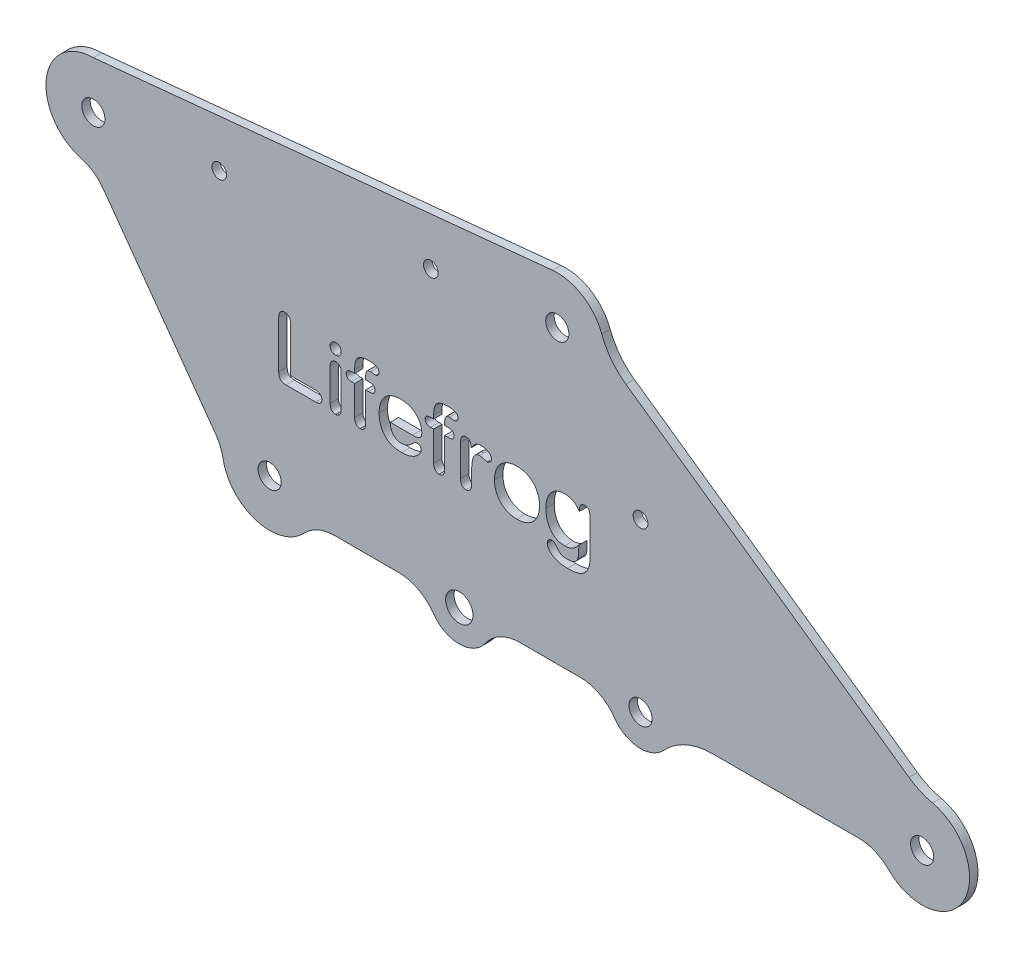
from build123d import *

# Parameters (mm, degrees)
SKETCH2_R           = 2.75
SKETCH2_R_2         = 3.25
BOSS_EXTRUDE1_DEPTH = 2
SKETCH7_R           = 1.75
CUT_EXTRUDE4_DEPTH  = 3
CUT_EXTRUDE5_DEPTH  = 10
SKETCH8_R           = 4.443707928
SKETCH8_R_2         = 3.98713944
CUT_EXTRUDE6_DEPTH  = 10


with BuildPart() as part:
    # Sketch2 → Boss-Extrude1 (new body)
    with BuildSketch(Plane.XY):
        with BuildLine():
            Line((-146.482261324, -3.415116213), (-119.900209046, -40.345357838))
            ThreePointArc((-119.900209046, -40.345357838), (-118.800607084, -42.305283789), (-118.166440512, -44.46126778))
            ThreePointArc((-118.166440512, -44.46126778), (-110.313224995, -53.296457195), (-98.896144571, -50.233151699))
            ThreePointArc((-98.896144571, -50.233151699), (-95.581387, -47.909162096), (-91.616909182, -47.089734824))
            Line((-91.616909182, -47.089734824), (-76.446691, -47.089734824))
            ThreePointArc((-76.446691, -47.089734824), (-71.817590501, -48.22568222), (-68.240172934, -51.37544911))
            ThreePointArc((-68.240172934, -51.37544911), (-62.085284384, -54.589734824), (-55.930395834, -51.37544911))
            ThreePointArc((-55.930395834, -51.37544911), (-52.352978266, -48.22568222), (-47.723877768, -47.089734824))
            Line((-47.723877768, -47.089734824), (-33.446691, -47.089734824))
            ThreePointArc((-33.446691, -47.089734824), (-28.817590501, -48.22568222), (-25.240172934, -51.37544911))
            ThreePointArc((-25.240172934, -51.37544911), (-19.593639667, -54.572486651), (-13.566591065, -52.168516573))
            ThreePointArc((-13.566591065, -52.168516573), (-8.311100334, -48.415273127), (-1.990501675, -47.089734824))
            Line((-1.990501675, -47.089734824), (32.686636747, -47.089734824))
            ThreePointArc((32.686636747, -47.089734824), (36.521461692, -47.854253372), (39.769927676, -50.030911295))
            ThreePointArc((39.769927676, -50.030911295), (57.590414229, -47.521571248), (50.200722675, -31.112458317))
            ThreePointArc((50.200722675, -31.112458317), (47.278407153, -30.14859154), (44.599620096, -28.63430389))
            Line((44.599620096, -28.63430389), (-22.564700668, 18.554547573))
            ThreePointArc((-22.564700668, 18.554547573), (-25.986792869, 21.830620173), (-28.278442139, 25.976908916))
            ThreePointArc((-28.278442139, 25.976908916), (-32.864492812, 31.616465892), (-39.941717654, 33.27458296))
            Line((-39.941717654, 33.27458296), (-148.918739614, 22.469864413))
            ThreePointArc((-148.918739614, 22.469864413), (-160.065949313, 12.737169894), (-151.925623591, 0.379147243))
            ThreePointArc((-151.925623591, 0.379147243), (-148.880072017, -1.053350399), (-146.482261324, -3.415116213))
        make_face()
        with Locations((47.738629971, -42.089734824)):
            Circle(SKETCH2_R, mode=Mode.SUBTRACT)
        with Locations((-19.085284384, -47.089734824)):
            Circle(SKETCH2_R, mode=Mode.SUBTRACT)
        with Locations((-62.085284384, -47.089734824)):
            Circle(SKETCH2_R_2, mode=Mode.SUBTRACT)
        with Locations((-107.085284384, -42.519495684)):
            Circle(SKETCH2_R, mode=Mode.SUBTRACT)
        with Locations((-148.918739614, 11.219864413)):
            Circle(SKETCH2_R, mode=Mode.SUBTRACT)
        with Locations((-38.831758764, 22.07947281)):
            Circle(SKETCH2_R, mode=Mode.SUBTRACT)
    extrude(amount=BOSS_EXTRUDE1_DEPTH)

    # Sketch7 → Cut-Extrude4 (cut, through all)
    with BuildSketch(Plane.XY.offset(2)):
        with Locations((-119.063647537, 14.164941171)):
            Circle(SKETCH7_R)
        with Locations((-68.831758764, 19.120101507)):
            Circle(SKETCH7_R)
        with Locations((-19.085284384, -7.519495684)):
            Circle(SKETCH7_R)
    extrude(amount=-CUT_EXTRUDE4_DEPTH, mode=Mode.SUBTRACT)

    # Sketch5 → Cut-Extrude5 (cut)
    with BuildSketch(Plane.XY.offset(2)):
        with BuildLine():
            Line((-102.115894244, -8.88917677), (-102.115894244, -19.477067395))
            Line((-102.115894244, -19.477067395), (-96.162769244, -19.477067395))
            add(Edge.make_bspline(
                [(-96.162769244, -19.477067395), (-96.051007313, -19.479993195), (-95.837884188, -19.485572515), (-95.539916783, -19.554542719), (-95.278875028, -19.661257744), (-95.067813968, -19.819951832), (-94.897692681, -20.005566477), (-94.774137444, -20.217869304), (-94.701867925, -20.454899643), (-94.69344353, -20.620129964), (-94.689136431, -20.704606457)],
                knots=[0, 0, 0, 0, 0.000334613, 0.000638087, 0.000912369, 0.001174294, 0.001423196, 0.001663395, 0.001905285, 0.002158326, 0.002158326, 0.002158326, 0.002158326], degree=3))
            add(Edge.make_bspline(
                [(-94.689136431, -20.704606457), (-94.693268201, -20.791061883), (-94.701260642, -20.958300126), (-94.774223839, -21.197153566), (-94.896313466, -21.407864411), (-95.064278317, -21.589554136), (-95.275076024, -21.739731647), (-95.534926018, -21.839448431), (-95.834238111, -21.905877279), (-96.049070498, -21.911559901), (-96.162769244, -21.914567395)],
                knots=[0, 0, 0, 0, 0.000258876, 0.000500766, 0.000740964, 0.000983563, 0.001237974, 0.001509993, 0.00181283, 0.002153292, 0.002153292, 0.002153292, 0.002153292], degree=3))
            Line((-96.162769244, -21.914567395), (-103.205737994, -21.914567395))
            add(Edge.make_bspline(
                [(-103.205737994, -21.914567395), (-103.348861132, -21.910822677), (-103.615411062, -21.903848583), (-103.983050705, -21.820051925), (-104.292130258, -21.691568649), (-104.538399287, -21.496286799), (-104.719909675, -21.2361672), (-104.844114456, -20.915092293), (-104.914328704, -20.530846545), (-104.923491067, -20.25471837), (-104.928394244, -20.106950207)],
                knots=[0, 0, 0, 0, 0.000428546, 0.000798117, 0.001124734, 0.001424881, 0.001727306, 0.002065149, 0.00245011, 0.002893278, 0.002893278, 0.002893278, 0.002893278], degree=3))
            Line((-104.928394244, -20.106950207), (-104.928394244, -8.88917677))
            add(Edge.make_bspline(
                [(-104.928394244, -8.88917677), (-104.924770448, -8.749162056), (-104.917946116, -8.485486372), (-104.845257533, -8.118037422), (-104.725580552, -7.804802622), (-104.557073154, -7.546892469), (-104.345359797, -7.348035389), (-104.103133358, -7.202614303), (-103.828238086, -7.118889739), (-103.635988236, -7.107793002), (-103.536792681, -7.102067395)],
                knots=[0, 0, 0, 0, 0.0004196, 0.000790191, 0.001117701, 0.00141997, 0.001705972, 0.001981814, 0.00226075, 0.002558095, 0.002558095, 0.002558095, 0.002558095], degree=3))
            add(Edge.make_bspline(
                [(-103.536792681, -7.102067395), (-103.435486672, -7.106162598), (-103.238729888, -7.114116312), (-102.960533725, -7.204196573), (-102.711018875, -7.34317393), (-102.496727467, -7.541754535), (-102.319699564, -7.795771782), (-102.199312355, -8.111096688), (-102.125957592, -8.481501141), (-102.119399349, -8.747181708), (-102.115894244, -8.88917677)],
                knots=[0, 0, 0, 0, 0.000302908, 0.000588308, 0.000867752, 0.001153903, 0.001457037, 0.001788351, 0.002158942, 0.002584392, 0.002584392, 0.002584392, 0.002584392], degree=3))
        make_face()
        with BuildLine():
            Line((-90.115894244, -12.74464552), (-90.115894244, -20.476090832))
            add(Edge.make_bspline(
                [(-90.115894244, -20.476090832), (-90.119794378, -20.602435528), (-90.127150905, -20.84074997), (-90.197032734, -21.174236118), (-90.314116621, -21.460321774), (-90.479508659, -21.694972614), (-90.682688675, -21.876468441), (-90.91257444, -22.009165841), (-91.170561441, -22.087195916), (-91.35072121, -22.097028675), (-91.443042681, -22.102067395)],
                knots=[0, 0, 0, 0, 0.000378656, 0.00071423, 0.001016215, 0.001299911, 0.001567541, 0.00182736, 0.002090575, 0.002367225, 0.002367225, 0.002367225, 0.002367225], degree=3))
            add(Edge.make_bspline(
                [(-91.443042681, -22.102067395), (-91.535510198, -22.097531408), (-91.714376796, -22.08875712), (-91.96856286, -22.004912745), (-92.195763486, -21.871389965), (-92.391201556, -21.682373157), (-92.551255931, -21.445866625), (-92.661127298, -21.160395096), (-92.729043835, -20.832780478), (-92.736793903, -20.599508451), (-92.740894244, -20.476090832)],
                knots=[0, 0, 0, 0, 0.00027665, 0.000535144, 0.000793904, 0.001061213, 0.001343984, 0.001643744, 0.001972979, 0.002342863, 0.002342863, 0.002342863, 0.002342863], degree=3))
            Line((-92.740894244, -20.476090832), (-92.740894244, -12.823747082))
            add(Edge.make_bspline(
                [(-92.740894244, -12.823747082), (-92.736699871, -12.699382119), (-92.728769083, -12.464230884), (-92.662517274, -12.136087305), (-92.551799881, -11.854229206), (-92.391012747, -11.625466775), (-92.194397213, -11.44586487), (-91.968144037, -11.317596829), (-91.713355602, -11.241954113), (-91.535359197, -11.232151465), (-91.443042681, -11.227067395)],
                knots=[0, 0, 0, 0, 0.000372808, 0.000704911, 0.000999239, 0.00127477, 0.001536087, 0.001791911, 0.002048673, 0.002325323, 0.002325323, 0.002325323, 0.002325323], degree=3))
            add(Edge.make_bspline(
                [(-91.443042681, -11.227067395), (-91.350780374, -11.232364163), (-91.171013808, -11.242684541), (-90.912920439, -11.316791228), (-90.682617286, -11.446472242), (-90.482415238, -11.624386887), (-90.315350707, -11.846010703), (-90.198859156, -12.112795725), (-90.127488314, -12.416719887), (-90.119879855, -12.631916842), (-90.115894244, -12.74464552)],
                knots=[0, 0, 0, 0, 0.00027665, 0.000539033, 0.000797411, 0.001063093, 0.001337313, 0.001623179, 0.001930167, 0.002267896, 0.002267896, 0.002267896, 0.002267896], degree=3))
        make_face()
        with BuildLine():
            add(Edge.make_bspline(
                [(-91.413745806, -9.914567395), (-91.502059692, -9.911112501), (-91.674377381, -9.904371326), (-91.923091601, -9.837014704), (-92.15078929, -9.726888524), (-92.357720239, -9.578448802), (-92.529720608, -9.386651845), (-92.655762931, -9.154497095), (-92.729492495, -8.885778489), (-92.73699213, -8.695310105), (-92.740894244, -8.59620802)],
                knots=[0, 0, 0, 0, 0.000264468, 0.000516029, 0.000766308, 0.001020043, 0.001275262, 0.001532224, 0.00180588, 0.002102705, 0.002102705, 0.002102705, 0.002102705], degree=3))
            add(Edge.make_bspline(
                [(-92.740894244, -8.59620802), (-92.735711958, -8.504891338), (-92.725668701, -8.327919822), (-92.650545078, -8.073896193), (-92.521388078, -7.848246813), (-92.347766447, -7.652100465), (-92.141388488, -7.494003153), (-91.916161531, -7.371969471), (-91.66963809, -7.303278473), (-91.500084931, -7.29419357), (-91.413745806, -7.289567395)],
                knots=[0, 0, 0, 0, 0.000273734, 0.000530495, 0.000786319, 0.001047867, 0.001310985, 0.001562597, 0.001812103, 0.002070978, 0.002070978, 0.002070978, 0.002070978], degree=3))
            add(Edge.make_bspline(
                [(-91.413745806, -7.289567395), (-91.330331688, -7.293289281), (-91.166969837, -7.300578386), (-90.929246738, -7.365176401), (-90.707981257, -7.471719022), (-90.506122496, -7.61868617), (-90.327667655, -7.801949122), (-90.205863506, -8.035133325), (-90.125225569, -8.302838261), (-90.119114728, -8.494958443), (-90.115894244, -8.59620802)],
                knots=[0, 0, 0, 0, 0.000249866, 0.000489349, 0.000733078, 0.000982721, 0.001235592, 0.001492554, 0.001764195, 0.002066861, 0.002066861, 0.002066861, 0.002066861], degree=3))
            add(Edge.make_bspline(
                [(-90.115894244, -8.59620802), (-90.119666741, -8.694407685), (-90.126915601, -8.883098506), (-90.202445242, -9.148438196), (-90.323346226, -9.381879948), (-90.497008149, -9.571319036), (-90.697722159, -9.722899361), (-90.920078487, -9.833786351), (-91.160369106, -9.904963009), (-91.328281937, -9.911327839), (-91.413745806, -9.914567395)],
                knots=[0, 0, 0, 0, 0.000293905, 0.000564738, 0.000820311, 0.00107553, 0.001328656, 0.001571042, 0.001817728, 0.002073434, 0.002073434, 0.002073434, 0.002073434], degree=3))
        make_face()
        with BuildLine():
            Line((-87.569995806, -11.414567395), (-86.928394244, -11.414567395))
            Line((-86.928394244, -11.414567395), (-86.928394244, -10.591325207))
            add(Edge.make_bspline(
                [(-86.928394244, -10.591325207), (-86.924700914, -10.388045332), (-86.917705381, -10.00301306), (-86.859665412, -9.457909943), (-86.765573069, -8.978381027), (-86.632882133, -8.557808501), (-86.446581198, -8.195572563), (-86.205604775, -7.887535194), (-85.908437152, -7.633608774), (-85.553484837, -7.431434885), (-85.135146039, -7.280410479), (-84.649682076, -7.174729198), (-84.094123419, -7.111487828), (-83.700058626, -7.105323868), (-83.491870806, -7.102067395)],
                knots=[0, 0, 0, 0, 0.00060972, 0.00115487, 0.001642098, 0.002073827, 0.00247349, 0.00285738, 0.003239656, 0.003638653, 0.004076188, 0.004568733, 0.005126183, 0.005750543, 0.005750543, 0.005750543, 0.005750543], degree=3))
            add(Edge.make_bspline(
                [(-83.491870806, -7.102067395), (-83.307068191, -7.104261268), (-82.960801066, -7.108371958), (-82.478567661, -7.168286024), (-82.066452312, -7.255167266), (-81.72918291, -7.391161667), (-81.457325514, -7.558653085), (-81.264450259, -7.776533401), (-81.14794255, -8.037027657), (-81.134555018, -8.223910447), (-81.127612994, -8.320817395)],
                knots=[0, 0, 0, 0, 0.00055399, 0.001038018, 0.001455897, 0.001813331, 0.002124554, 0.002404841, 0.002673751, 0.002963375, 0.002963375, 0.002963375, 0.002963375], degree=3))
            add(Edge.make_bspline(
                [(-81.127612994, -8.320817395), (-81.13016044, -8.384563693), (-81.135172155, -8.509974928), (-81.182649106, -8.690669099), (-81.264942883, -8.855101057), (-81.371125512, -9.002344218), (-81.498609867, -9.125761707), (-81.641283549, -9.215318606), (-81.796289851, -9.272564588), (-81.904462105, -9.278650351), (-81.959644244, -9.281754895)],
                knots=[0, 0, 0, 0, 0.000190992, 0.000375748, 0.00055525, 0.000739844, 0.00091805, 0.001083881, 0.001242328, 0.00140733, 0.00140733, 0.00140733, 0.00140733], degree=3))
            add(Edge.make_bspline(
                [(-81.959644244, -9.281754895), (-81.990923875, -9.281243662), (-82.062451162, -9.280074624), (-82.184322966, -9.265550853), (-82.335069813, -9.249871502), (-82.562596635, -9.213428957), (-82.838380297, -9.175272517), (-83.05620293, -9.167906783), (-83.154956744, -9.164567395)],
                knots=[0, 0, 0, 0, 9.3796e-05, 0.000214483, 0.000367838, 0.000548483, 0.000905689, 0.00120195, 0.00120195, 0.00120195, 0.00120195], degree=3))
            add(Edge.make_bspline(
                [(-83.154956744, -9.164567395), (-83.266879767, -9.168513751), (-83.471705369, -9.175735811), (-83.748826522, -9.253609551), (-83.965776352, -9.387787922), (-84.108374405, -9.587280743), (-84.19515756, -9.82836939), (-84.25744231, -10.108223991), (-84.299579902, -10.432859402), (-84.302069643, -10.66441903), (-84.303394244, -10.78761427)],
                knots=[0, 0, 0, 0, 0.000335024, 0.000613112, 0.000854452, 0.001084726, 0.001333353, 0.001619039, 0.001943904, 0.00231323, 0.00231323, 0.00231323, 0.00231323], degree=3))
            Line((-84.303394244, -10.78761427), (-84.303394244, -11.414567395))
            Line((-84.303394244, -11.414567395), (-83.638355181, -11.414567395))
            add(Edge.make_bspline(
                [(-83.638355181, -11.414567395), (-83.518035883, -11.416649074), (-83.291972191, -11.420560268), (-82.976422378, -11.467875581), (-82.70599729, -11.540251074), (-82.484005335, -11.648680399), (-82.308648107, -11.789413733), (-82.185554218, -11.965226471), (-82.107884225, -12.172143548), (-82.10096014, -12.32106946), (-82.097339556, -12.398942395)],
                knots=[0, 0, 0, 0, 0.000360649, 0.000677611, 0.000954881, 0.001197267, 0.001413707, 0.001621798, 0.001834054, 0.002066683, 0.002066683, 0.002066683, 0.002066683], degree=3))
            add(Edge.make_bspline(
                [(-82.097339556, -12.398942395), (-82.101430239, -12.506003658), (-82.10888127, -12.701011923), (-82.184683124, -12.965095468), (-82.314039334, -13.171513058), (-82.509943835, -13.302589493), (-82.740907301, -13.37783369), (-83.005840503, -13.437731598), (-83.309405986, -13.470942071), (-83.525001195, -13.474956644), (-83.638355181, -13.477067395)],
                knots=[0, 0, 0, 0, 0.000320423, 0.000583638, 0.000816027, 0.001034677, 0.001274715, 0.00154196, 0.001848669, 0.002188714, 0.002188714, 0.002188714, 0.002188714], degree=3))
            Line((-83.638355181, -13.477067395), (-84.303394244, -13.477067395))
            Line((-84.303394244, -13.477067395), (-84.303394244, -20.49073927))
            add(Edge.make_bspline(
                [(-84.303394244, -20.49073927), (-84.307324323, -20.614179922), (-84.314789501, -20.848655192), (-84.385280454, -21.176561155), (-84.498848793, -21.461585314), (-84.664152095, -21.695052259), (-84.866845108, -21.875428653), (-85.095501488, -22.010618694), (-85.355317063, -22.086940159), (-85.537294849, -22.096942211), (-85.630542681, -22.102067395)],
                knots=[0, 0, 0, 0, 0.000369884, 0.000702594, 0.001000746, 0.001284442, 0.001552072, 0.001809351, 0.002075373, 0.002354939, 0.002354939, 0.002354939, 0.002354939], degree=3))
            add(Edge.make_bspline(
                [(-85.630542681, -22.102067395), (-85.719989993, -22.09710813), (-85.894515188, -22.087431855), (-86.145054229, -22.007724342), (-86.370556982, -21.876461922), (-86.570766574, -21.694722042), (-86.732567229, -21.460721404), (-86.846686793, -21.176665365), (-86.916946166, -20.8486244), (-86.924445947, -20.614169302), (-86.928394244, -20.49073927)],
                knots=[0, 0, 0, 0, 0.000267902, 0.000522718, 0.000779997, 0.001045453, 0.001327465, 0.001625617, 0.001958327, 0.002328211, 0.002328211, 0.002328211, 0.002328211], degree=3))
            Line((-86.928394244, -20.49073927), (-86.928394244, -13.477067395))
            Line((-86.928394244, -13.477067395), (-87.669605181, -13.477067395))
            add(Edge.make_bspline(
                [(-87.669605181, -13.477067395), (-87.764717637, -13.474545828), (-87.945069974, -13.469764431), (-88.197602841, -13.411306638), (-88.420159882, -13.326305771), (-88.603573939, -13.197615767), (-88.750908304, -13.041843238), (-88.850169927, -12.858126156), (-88.916372739, -12.656347119), (-88.923007314, -12.513757181), (-88.926441119, -12.43995802)],
                knots=[0, 0, 0, 0, 0.000284723, 0.000539892, 0.000773827, 0.000994878, 0.001206343, 0.00141094, 0.001616645, 0.001837326, 0.001837326, 0.001837326, 0.001837326], degree=3))
            add(Edge.make_bspline(
                [(-88.926441119, -12.43995802), (-88.923283957, -12.359364997), (-88.9172753, -12.205981751), (-88.850749549, -11.99217143), (-88.742401324, -11.809230275), (-88.589026748, -11.659732473), (-88.391857426, -11.547566221), (-88.154756492, -11.470404208), (-87.876811847, -11.419710271), (-87.676697567, -11.416355939), (-87.569995806, -11.414567395)],
                knots=[0, 0, 0, 0, 0.000241108, 0.000458873, 0.000663867, 0.000873109, 0.001093694, 0.001338283, 0.001618141, 0.001937813, 0.001937813, 0.001937813, 0.001937813], degree=3))
        make_face()
        with BuildLine():
            Line((-73.208667681, -17.227067395), (-78.490894244, -17.227067395))
            add(Edge.make_bspline(
                [(-78.490894244, -17.227067395), (-78.485729032, -17.373895282), (-78.475607796, -17.661604604), (-78.399500086, -18.07799563), (-78.286354508, -18.469071713), (-78.128567635, -18.829619398), (-77.931660235, -19.153364248), (-77.709449566, -19.442705533), (-77.451707834, -19.684973297), (-77.165756761, -19.88267243), (-76.856444567, -20.033615445), (-76.531732066, -20.148105778), (-76.18967889, -20.212156224), (-75.956959932, -20.222066531), (-75.839527056, -20.227067395)],
                knots=[0, 0, 0, 0, 0.000440243, 0.000862657, 0.001265902, 0.001659452, 0.002039296, 0.002400313, 0.002750567, 0.003095948, 0.003439221, 0.003780175, 0.004126076, 0.004478419, 0.004478419, 0.004478419, 0.004478419], degree=3))
            add(Edge.make_bspline(
                [(-75.839527056, -20.227067395), (-75.684899945, -20.221290078), (-75.38699415, -20.210159454), (-74.953894078, -20.128402077), (-74.55183901, -19.976572402), (-74.172233727, -19.770423211), (-73.819626408, -19.521193305), (-73.535198858, -19.296133613), (-73.30788746, -19.094787244), (-73.116419912, -18.918875484), (-72.897546603, -18.722900775), (-72.746482696, -18.581855292), (-72.666675494, -18.507340832)],
                knots=[0, 0, 0, 0, 0.000463817, 0.000893593, 0.001315356, 0.001747919, 0.002185944, 0.00260917, 0.00283544, 0.003096758, 0.003389213, 0.003716762, 0.003716762, 0.003716762, 0.003716762], degree=3))
            add(Edge.make_bspline(
                [(-72.666675494, -18.507340832), (-72.629561272, -18.48027204), (-72.552305707, -18.423926662), (-72.410745358, -18.369543996), (-72.248164227, -18.338198915), (-72.132654468, -18.333846809), (-72.071948931, -18.331559582)],
                knots=[0, 0, 0, 0, 0.000137321, 0.000285842, 0.000450166, 0.000632184, 0.000632184, 0.000632184, 0.000632184], degree=3))
            add(Edge.make_bspline(
                [(-72.071948931, -18.331559582), (-72.005205088, -18.333900139), (-71.877920585, -18.33836372), (-71.698147996, -18.385198991), (-71.535535781, -18.453914722), (-71.397435702, -18.559309462), (-71.281141949, -18.686697731), (-71.200775579, -18.843467551), (-71.148932879, -19.021621344), (-71.145191899, -19.149522649), (-71.143237994, -19.216325207)],
                knots=[0, 0, 0, 0, 0.000199757, 0.000380948, 0.000554072, 0.000725753, 0.000898008, 0.001067069, 0.001249769, 0.001449526, 0.001449526, 0.001449526, 0.001449526], degree=3))
            add(Edge.make_bspline(
                [(-71.143237994, -19.216325207), (-71.147074427, -19.281058441), (-71.155207149, -19.418284177), (-71.211530831, -19.630580971), (-71.30468497, -19.856403047), (-71.430534653, -20.095129398), (-71.589870145, -20.341196211), (-71.792561168, -20.580823639), (-72.027283373, -20.819411181), (-72.299993333, -21.049528185), (-72.606870884, -21.269822809), (-72.952879871, -21.470546591), (-73.33797498, -21.646257285), (-73.755957021, -21.809324299), (-74.209350401, -21.941257019), (-74.697887614, -22.0333954), (-75.217872478, -22.094193404), (-75.576651345, -22.099400308), (-75.760425494, -22.102067395)],
                knots=[0, 0, 0, 0, 0.000194157, 0.000411586, 0.000654768, 0.000926029, 0.001220182, 0.001532273, 0.001865807, 0.002223301, 0.002601333, 0.002997794, 0.003421152, 0.003870016, 0.004342868, 0.004835273, 0.005360039, 0.005911101, 0.005911101, 0.005911101, 0.005911101], degree=3))
            add(Edge.make_bspline(
                [(-75.760425494, -22.102067395), (-75.970566234, -22.097519737), (-76.380250285, -22.088653761), (-76.975430681, -22.021353682), (-77.533004004, -21.908362258), (-78.051645226, -21.745772772), (-78.534701665, -21.542562166), (-78.978161462, -21.288395048), (-79.381535863, -20.987522623), (-79.746754804, -20.64373407), (-80.067772398, -20.257975864), (-80.351874822, -19.841633038), (-80.585884137, -19.388813691), (-80.780372736, -18.905299727), (-80.932098867, -18.389217889), (-81.040075091, -17.840151988), (-81.10545073, -17.258936562), (-81.112357264, -16.86005426), (-81.115894244, -16.655778332)],
                knots=[0, 0, 0, 0, 0.000630319, 0.00122885, 0.001794227, 0.002334443, 0.002856848, 0.003363404, 0.003863798, 0.004363265, 0.004864412, 0.005366578, 0.005872397, 0.006390314, 0.006927974, 0.007483573, 0.00806722, 0.008679868, 0.008679868, 0.008679868, 0.008679868], degree=3))
            add(Edge.make_bspline(
                [(-81.115894244, -16.655778332), (-81.112351374, -16.462226663), (-81.105370439, -16.080848933), (-81.038259091, -15.519624607), (-80.933763598, -14.979723953), (-80.788486547, -14.462108781), (-80.598046656, -13.975533109), (-80.372921593, -13.519340339), (-80.104117762, -13.102077052), (-79.799927638, -12.718106315), (-79.451233704, -12.376213514), (-79.061234287, -12.074737303), (-78.628998548, -11.817183613), (-78.157129599, -11.603132446), (-77.650787767, -11.433045112), (-77.112381625, -11.315293392), (-76.545831122, -11.238702527), (-76.158145954, -11.231007425), (-75.959644244, -11.227067395)],
                knots=[0, 0, 0, 0, 0.000580441, 0.001143711, 0.001692994, 0.002229023, 0.002754034, 0.003258459, 0.00375257, 0.004240308, 0.00472508, 0.005213803, 0.005715738, 0.006230972, 0.006765533, 0.007314957, 0.007882205, 0.008477394, 0.008477394, 0.008477394, 0.008477394], degree=3))
            add(Edge.make_bspline(
                [(-75.959644244, -11.227067395), (-75.82967599, -11.22810589), (-75.575169739, -11.23013949), (-75.200806959, -11.265268194), (-74.839711595, -11.313850777), (-74.491487894, -11.382379075), (-74.15967654, -11.478141357), (-73.841160582, -11.589179566), (-73.536096258, -11.720379466), (-73.247093024, -11.874248291), (-72.971225393, -12.038773815), (-72.717190296, -12.223475089), (-72.475441109, -12.411434191), (-72.254440606, -12.616494045), (-72.04918298, -12.831425773), (-71.86543806, -13.06140635), (-71.695754099, -13.299708893), (-71.501065769, -13.632045496), (-71.29721699, -14.058699678), (-71.115470707, -14.582630241), (-71.005629179, -15.115069491), (-70.991884998, -15.472667779), (-70.985034869, -15.65089552)],
                knots=[0, 0, 0, 0, 0.000389748, 0.000763211, 0.001126988, 0.00148264, 0.001826713, 0.002162134, 0.002494121, 0.002821735, 0.003143801, 0.003456784, 0.003763339, 0.004061909, 0.004360335, 0.004654079, 0.004944251, 0.005237176, 0.005808517, 0.006359774, 0.006897561, 0.007431922, 0.007431922, 0.007431922, 0.007431922], degree=3))
            add(Edge.make_bspline(
                [(-70.985034869, -15.65089552), (-70.986604018, -15.730068621), (-70.989597069, -15.881086234), (-71.015277956, -16.097314554), (-71.061442947, -16.291180146), (-71.127161718, -16.464024902), (-71.206726919, -16.617172785), (-71.3094301, -16.74579461), (-71.428239515, -16.854326494), (-71.620032975, -16.968584464), (-71.901445225, -17.07492862), (-72.285671015, -17.164445981), (-72.727625927, -17.219117531), (-73.042486482, -17.224321026), (-73.208667681, -17.227067395)],
                knots=[0, 0, 0, 0, 0.000237467, 0.000452954, 0.000651914, 0.000833649, 0.001006674, 0.001167274, 0.001324933, 0.00148673, 0.001833821, 0.00222251, 0.002668381, 0.003166738, 0.003166738, 0.003166738, 0.003166738], degree=3))
        make_face()
        with BuildLine():
            Line((-78.490894244, -15.727067395), (-73.595386431, -15.727067395))
            add(Edge.make_bspline(
                [(-73.595386431, -15.727067395), (-73.604322953, -15.620388862), (-73.621708392, -15.412852503), (-73.676971373, -15.113999216), (-73.741925544, -14.835108466), (-73.828072086, -14.577543089), (-73.929671959, -14.341165405), (-74.047709808, -14.123236857), (-74.184828665, -13.928050969), (-74.338373242, -13.753386376), (-74.507240019, -13.600302554), (-74.687703579, -13.465060191), (-74.88367525, -13.352382039), (-75.092871169, -13.262997606), (-75.31249975, -13.187447347), (-75.546992381, -13.140138129), (-75.792574806, -13.105158478), (-75.961461832, -13.103110926), (-76.047534869, -13.102067395)],
                knots=[0, 0, 0, 0, 0.000320958, 0.000624403, 0.000910764, 0.001179435, 0.001437945, 0.001681814, 0.001921584, 0.002151988, 0.00237803, 0.002604205, 0.002827324, 0.003054294, 0.003285906, 0.00352265, 0.003770844, 0.004028807, 0.004028807, 0.004028807, 0.004028807], degree=3))
            add(Edge.make_bspline(
                [(-76.047534869, -13.102067395), (-76.129637456, -13.10475237), (-76.290452304, -13.110011447), (-76.527254178, -13.138599654), (-76.752039842, -13.191199261), (-76.965729073, -13.265652746), (-77.168337697, -13.359118289), (-77.35978224, -13.474146939), (-77.539458013, -13.609700616), (-77.706839063, -13.766189336), (-77.862846038, -13.941320054), (-78.000334453, -14.138573533), (-78.120382782, -14.355594311), (-78.229866787, -14.589561112), (-78.320263624, -14.845787112), (-78.392374485, -15.122470817), (-78.451283959, -15.417941176), (-78.477480377, -15.622383021), (-78.490894244, -15.727067395)],
                knots=[0, 0, 0, 0, 0.000246373, 0.000482572, 0.000714239, 0.000937531, 0.00116036, 0.001382438, 0.001606266, 0.001834293, 0.002068833, 0.002308603, 0.002553893, 0.002812121, 0.003082701, 0.003367665, 0.003669309, 0.003985851, 0.003985851, 0.003985851, 0.003985851], degree=3))
        make_face(mode=Mode.SUBTRACT)
        with BuildLine():
            Line((-68.819995806, -11.414567395), (-68.178394244, -11.414567395))
            Line((-68.178394244, -11.414567395), (-68.178394244, -10.591325207))
            add(Edge.make_bspline(
                [(-68.178394244, -10.591325207), (-68.174700914, -10.388045332), (-68.167705381, -10.00301306), (-68.109665412, -9.457909943), (-68.015573069, -8.978381027), (-67.882882133, -8.557808501), (-67.696581198, -8.195572563), (-67.455604775, -7.887535194), (-67.158437152, -7.633608774), (-66.803484837, -7.431434885), (-66.385146039, -7.280410479), (-65.899682076, -7.174729198), (-65.344123419, -7.111487828), (-64.950058626, -7.105323868), (-64.741870806, -7.102067395)],
                knots=[0, 0, 0, 0, 0.00060972, 0.00115487, 0.001642098, 0.002073827, 0.00247349, 0.00285738, 0.003239656, 0.003638653, 0.004076188, 0.004568733, 0.005126183, 0.005750543, 0.005750543, 0.005750543, 0.005750543], degree=3))
            add(Edge.make_bspline(
                [(-64.741870806, -7.102067395), (-64.557068191, -7.104261268), (-64.210801066, -7.108371958), (-63.728567661, -7.168286024), (-63.316452312, -7.255167266), (-62.97918291, -7.391161667), (-62.707325514, -7.558653085), (-62.514450259, -7.776533401), (-62.39794255, -8.037027657), (-62.384555018, -8.223910447), (-62.377612994, -8.320817395)],
                knots=[0, 0, 0, 0, 0.00055399, 0.001038018, 0.001455897, 0.001813331, 0.002124554, 0.002404841, 0.002673751, 0.002963375, 0.002963375, 0.002963375, 0.002963375], degree=3))
            add(Edge.make_bspline(
                [(-62.377612994, -8.320817395), (-62.38016044, -8.384563693), (-62.385172155, -8.509974928), (-62.432649106, -8.690669099), (-62.514942883, -8.855101057), (-62.621125512, -9.002344218), (-62.748609867, -9.125761707), (-62.891283549, -9.215318606), (-63.046289851, -9.272564588), (-63.154462105, -9.278650351), (-63.209644244, -9.281754895)],
                knots=[0, 0, 0, 0, 0.000190992, 0.000375748, 0.00055525, 0.000739844, 0.00091805, 0.001083881, 0.001242328, 0.00140733, 0.00140733, 0.00140733, 0.00140733], degree=3))
            add(Edge.make_bspline(
                [(-63.209644244, -9.281754895), (-63.240923875, -9.281243662), (-63.312451162, -9.280074624), (-63.434322966, -9.265550853), (-63.585069813, -9.249871502), (-63.812596635, -9.213428957), (-64.088380297, -9.175272517), (-64.30620293, -9.167906783), (-64.404956744, -9.164567395)],
                knots=[0, 0, 0, 0, 9.3796e-05, 0.000214483, 0.000367838, 0.000548483, 0.000905689, 0.00120195, 0.00120195, 0.00120195, 0.00120195], degree=3))
            add(Edge.make_bspline(
                [(-64.404956744, -9.164567395), (-64.516879767, -9.168513751), (-64.721705369, -9.175735811), (-64.998826522, -9.253609551), (-65.215776352, -9.387787922), (-65.358374405, -9.587280743), (-65.44515756, -9.82836939), (-65.50744231, -10.108223991), (-65.549579902, -10.432859402), (-65.552069643, -10.66441903), (-65.553394244, -10.78761427)],
                knots=[0, 0, 0, 0, 0.000335024, 0.000613112, 0.000854452, 0.001084726, 0.001333353, 0.001619039, 0.001943904, 0.00231323, 0.00231323, 0.00231323, 0.00231323], degree=3))
            Line((-65.553394244, -10.78761427), (-65.553394244, -11.414567395))
            Line((-65.553394244, -11.414567395), (-64.888355181, -11.414567395))
            add(Edge.make_bspline(
                [(-64.888355181, -11.414567395), (-64.768035883, -11.416649074), (-64.541972191, -11.420560268), (-64.226422378, -11.467875581), (-63.95599729, -11.540251074), (-63.734005335, -11.648680399), (-63.558648107, -11.789413733), (-63.435554218, -11.965226471), (-63.357884225, -12.172143548), (-63.35096014, -12.32106946), (-63.347339556, -12.398942395)],
                knots=[0, 0, 0, 0, 0.000360649, 0.000677611, 0.000954881, 0.001197267, 0.001413707, 0.001621798, 0.001834054, 0.002066683, 0.002066683, 0.002066683, 0.002066683], degree=3))
            add(Edge.make_bspline(
                [(-63.347339556, -12.398942395), (-63.351430239, -12.506003658), (-63.35888127, -12.701011923), (-63.434683124, -12.965095468), (-63.564039334, -13.171513058), (-63.759943835, -13.302589493), (-63.990907301, -13.37783369), (-64.255840503, -13.437731598), (-64.559405986, -13.470942071), (-64.775001195, -13.474956644), (-64.888355181, -13.477067395)],
                knots=[0, 0, 0, 0, 0.000320423, 0.000583638, 0.000816027, 0.001034677, 0.001274715, 0.00154196, 0.001848669, 0.002188714, 0.002188714, 0.002188714, 0.002188714], degree=3))
            Line((-64.888355181, -13.477067395), (-65.553394244, -13.477067395))
            Line((-65.553394244, -13.477067395), (-65.553394244, -20.49073927))
            add(Edge.make_bspline(
                [(-65.553394244, -20.49073927), (-65.557324323, -20.614179922), (-65.564789501, -20.848655192), (-65.635280454, -21.176561155), (-65.748848793, -21.461585314), (-65.914152095, -21.695052259), (-66.116845108, -21.875428653), (-66.345501488, -22.010618694), (-66.605317063, -22.086940159), (-66.787294849, -22.096942211), (-66.880542681, -22.102067395)],
                knots=[0, 0, 0, 0, 0.000369884, 0.000702594, 0.001000746, 0.001284442, 0.001552072, 0.001809351, 0.002075373, 0.002354939, 0.002354939, 0.002354939, 0.002354939], degree=3))
            add(Edge.make_bspline(
                [(-66.880542681, -22.102067395), (-66.969989993, -22.09710813), (-67.144515188, -22.087431855), (-67.395054229, -22.007724342), (-67.620556982, -21.876461922), (-67.820766574, -21.694722042), (-67.982567229, -21.460721404), (-68.096686793, -21.176665365), (-68.166946166, -20.8486244), (-68.174445947, -20.614169302), (-68.178394244, -20.49073927)],
                knots=[0, 0, 0, 0, 0.000267902, 0.000522718, 0.000779997, 0.001045453, 0.001327465, 0.001625617, 0.001958327, 0.002328211, 0.002328211, 0.002328211, 0.002328211], degree=3))
            Line((-68.178394244, -20.49073927), (-68.178394244, -13.477067395))
            Line((-68.178394244, -13.477067395), (-68.919605181, -13.477067395))
            add(Edge.make_bspline(
                [(-68.919605181, -13.477067395), (-69.014717637, -13.474545828), (-69.195069974, -13.469764431), (-69.447602841, -13.411306638), (-69.670159882, -13.326305771), (-69.853573939, -13.197615767), (-70.000908304, -13.041843238), (-70.100169927, -12.858126156), (-70.166372739, -12.656347119), (-70.173007314, -12.513757181), (-70.176441119, -12.43995802)],
                knots=[0, 0, 0, 0, 0.000284723, 0.000539892, 0.000773827, 0.000994878, 0.001206343, 0.00141094, 0.001616645, 0.001837326, 0.001837326, 0.001837326, 0.001837326], degree=3))
            add(Edge.make_bspline(
                [(-70.176441119, -12.43995802), (-70.173283957, -12.359364997), (-70.1672753, -12.205981751), (-70.100749549, -11.99217143), (-69.992401324, -11.809230275), (-69.839026748, -11.659732473), (-69.641857426, -11.547566221), (-69.404756492, -11.470404208), (-69.126811847, -11.419710271), (-68.926697567, -11.416355939), (-68.819995806, -11.414567395)],
                knots=[0, 0, 0, 0, 0.000241108, 0.000458873, 0.000663867, 0.000873109, 0.001093694, 0.001338283, 0.001618141, 0.001937813, 0.001937813, 0.001937813, 0.001937813], degree=3))
        make_face()
        with BuildLine():
            Line((-59.178394244, -18.21730177), (-59.178394244, -20.464372082))
            add(Edge.make_bspline(
                [(-59.178394244, -20.464372082), (-59.182322559, -20.592663462), (-59.189737847, -20.83483283), (-59.259216665, -21.173173015), (-59.375819591, -21.46268977), (-59.542206957, -21.697626109), (-59.744323108, -21.879946249), (-59.975989208, -22.008518529), (-60.232941334, -22.08740627), (-60.413180516, -22.097099946), (-60.505542681, -22.102067395)],
                knots=[0, 0, 0, 0, 0.000384504, 0.000725809, 0.001030497, 0.001314193, 0.001581823, 0.001840201, 0.002103416, 0.002380066, 0.002380066, 0.002380066, 0.002380066], degree=3))
            add(Edge.make_bspline(
                [(-60.505542681, -22.102067395), (-60.596898089, -22.09710505), (-60.774228669, -22.087472609), (-61.02762995, -22.009227395), (-61.251604297, -21.875274697), (-61.451984506, -21.695716107), (-61.610499532, -21.458957778), (-61.725504258, -21.174115576), (-61.791218668, -20.840355995), (-61.799173407, -20.602368539), (-61.803394244, -20.476090832)],
                knots=[0, 0, 0, 0, 0.000273734, 0.000531346, 0.000786095, 0.001051551, 0.001331899, 0.00163276, 0.001967732, 0.002346388, 0.002346388, 0.002346388, 0.002346388], degree=3))
            Line((-61.803394244, -20.476090832), (-61.803394244, -13.028825207))
            add(Edge.make_bspline(
                [(-61.803394244, -13.028825207), (-61.799730251, -12.887967816), (-61.792849053, -12.623429237), (-61.735776236, -12.253599122), (-61.639567719, -11.937580399), (-61.496254001, -11.678454634), (-61.315514017, -11.470839169), (-61.086826968, -11.325648529), (-60.817640573, -11.24325969), (-60.626241318, -11.232631094), (-60.526050494, -11.227067395)],
                knots=[0, 0, 0, 0, 0.000422373, 0.000793242, 0.001119373, 0.001407914, 0.001675543, 0.001936417, 0.002209759, 0.00251002, 0.00251002, 0.00251002, 0.00251002], degree=3))
            add(Edge.make_bspline(
                [(-60.526050494, -11.227067395), (-60.423964078, -11.23166171), (-60.232140874, -11.240294554), (-59.96573528, -11.31618665), (-59.744757761, -11.448839438), (-59.574502888, -11.63900255), (-59.444204249, -11.876050227), (-59.349609385, -12.159893812), (-59.290006047, -12.492418163), (-59.274520952, -12.729745798), (-59.266284869, -12.855973645)],
                knots=[0, 0, 0, 0, 0.000305826, 0.000574656, 0.000821863, 0.001068601, 0.001330968, 0.001628371, 0.001962214, 0.002341515, 0.002341515, 0.002341515, 0.002341515], degree=3))
            add(Edge.make_bspline(
                [(-59.266284869, -12.855973645), (-59.187154757, -12.728702257), (-59.035804418, -12.485273209), (-58.787956133, -12.155879517), (-58.540962339, -11.872664951), (-58.284149984, -11.635812705), (-58.002222316, -11.445181426), (-57.676391936, -11.317799074), (-57.309909313, -11.240889927), (-57.051850669, -11.231818927), (-56.916675494, -11.227067395)],
                knots=[0, 0, 0, 0, 0.000449399, 0.000859555, 0.001235207, 0.001575354, 0.001905253, 0.002249625, 0.002617939, 0.003023095, 0.003023095, 0.003023095, 0.003023095], degree=3))
            add(Edge.make_bspline(
                [(-56.916675494, -11.227067395), (-56.775747725, -11.232489358), (-56.492853461, -11.243373249), (-56.073052378, -11.320929872), (-55.660920655, -11.453132582), (-55.328766913, -11.600397905), (-55.080670801, -11.742608322), (-54.915701672, -11.857020394), (-54.778751657, -11.98382965), (-54.661785388, -12.115426572), (-54.572123596, -12.257833616), (-54.510761789, -12.409798496), (-54.470136727, -12.569674136), (-54.466414535, -12.679941298), (-54.464527056, -12.735856457)],
                knots=[0, 0, 0, 0, 0.000422698, 0.000848512, 0.001275654, 0.00171888, 0.001935459, 0.00213299, 0.002319618, 0.002494076, 0.002659908, 0.002821493, 0.002984216, 0.003151619, 0.003151619, 0.003151619, 0.003151619], degree=3))
            add(Edge.make_bspline(
                [(-54.464527056, -12.735856457), (-54.467767369, -12.813574254), (-54.474044563, -12.9641306), (-54.543416205, -13.177988977), (-54.648650468, -13.372817877), (-54.799251598, -13.536083886), (-54.970071927, -13.670264449), (-55.15351986, -13.768279515), (-55.34434546, -13.830801857), (-55.474819056, -13.839133704), (-55.539722369, -13.843278332)],
                knots=[0, 0, 0, 0, 0.000232352, 0.000450117, 0.000667803, 0.000891881, 0.00111106, 0.001316827, 0.001513269, 0.001707713, 0.001707713, 0.001707713, 0.001707713], degree=3))
            add(Edge.make_bspline(
                [(-55.539722369, -13.843278332), (-55.573036344, -13.840040056), (-55.659230674, -13.831661558), (-55.81195832, -13.792022204), (-56.018474751, -13.737267753), (-56.263119245, -13.659990651), (-56.524940328, -13.576472525), (-56.786413638, -13.523477689), (-57.029774565, -13.484406004), (-57.187045252, -13.479444147), (-57.262378619, -13.477067395)],
                knots=[0, 0, 0, 0, 0.000100296, 0.0002595, 0.000471998, 0.000741673, 0.001029021, 0.001295639, 0.001541331, 0.001767221, 0.001767221, 0.001767221, 0.001767221], degree=3))
            add(Edge.make_bspline(
                [(-57.262378619, -13.477067395), (-57.356325896, -13.48141761), (-57.53814264, -13.489836608), (-57.799778543, -13.542788927), (-58.031283068, -13.646030446), (-58.238408899, -13.78176069), (-58.417017735, -13.961357491), (-58.574777615, -14.175620461), (-58.709682748, -14.42885195), (-58.822549933, -14.716376161), (-58.914044921, -15.037011302), (-58.992795855, -15.386257938), (-59.057640423, -15.764579045), (-59.102562652, -16.17561647), (-59.138042073, -16.623081436), (-59.159869077, -17.113612554), (-59.17481521, -17.649826852), (-59.177168503, -18.022954037), (-59.178394244, -18.21730177)],
                knots=[0, 0, 0, 0, 0.000281997, 0.00054575, 0.000795032, 0.001037984, 0.001284513, 0.001550535, 0.001833686, 0.002142695, 0.002475508, 0.002833002, 0.003216388, 0.003626303, 0.004073002, 0.00456282, 0.005099153, 0.005682191, 0.005682191, 0.005682191, 0.005682191], degree=3))
        make_face()
        with BuildLine():
            add(Edge.make_bspline(
                [(-43.053394244, -16.67042677), (-43.057728542, -16.865958198), (-43.066252796, -17.250509443), (-43.138520017, -17.815248603), (-43.254958537, -18.356735194), (-43.419004374, -18.872727585), (-43.626659138, -19.359535852), (-43.875574702, -19.813005753), (-44.168674914, -20.230278447), (-44.502042283, -20.609939276), (-44.87324689, -20.9531364), (-45.282555715, -21.251299839), (-45.724083256, -21.51184656), (-46.201220039, -21.724708392), (-46.709713134, -21.896725611), (-47.251272277, -22.014013606), (-47.821725836, -22.090278252), (-48.212318248, -22.098082029), (-48.411792681, -22.102067395)],
                knots=[0, 0, 0, 0, 0.000586406, 0.001153284, 0.001704937, 0.002246033, 0.002774978, 0.003290312, 0.003795052, 0.004301608, 0.004803364, 0.005308469, 0.005817966, 0.006338536, 0.006873097, 0.00742538, 0.007998439, 0.008596555, 0.008596555, 0.008596555, 0.008596555], degree=3))
            add(Edge.make_bspline(
                [(-48.411792681, -22.102067395), (-48.610344042, -22.098480665), (-48.998254853, -22.091473252), (-49.563292355, -22.010038917), (-50.100636847, -21.894122427), (-50.604396012, -21.719498742), (-51.077288647, -21.501305834), (-51.517614652, -21.240748892), (-51.924440792, -20.936460383), (-52.297338455, -20.593622978), (-52.632320931, -20.211571465), (-52.925158164, -19.794745386), (-53.17711555, -19.345794671), (-53.380776906, -18.863747925), (-53.543433899, -18.352053245), (-53.654803996, -17.811904116), (-53.728424871, -17.246665517), (-53.736684315, -16.861096277), (-53.740894244, -16.664567395)],
                knots=[0, 0, 0, 0, 0.000595188, 0.001162822, 0.001709388, 0.002242116, 0.002758572, 0.003269557, 0.003774051, 0.004279946, 0.004786502, 0.005295324, 0.005805536, 0.006327941, 0.006862567, 0.007413605, 0.007980483, 0.008569816, 0.008569816, 0.008569816, 0.008569816], degree=3))
            add(Edge.make_bspline(
                [(-53.740894244, -16.664567395), (-53.736700746, -16.466082785), (-53.728472249, -16.076615619), (-53.654590223, -15.505610155), (-53.544112506, -14.959085186), (-53.377821625, -14.441866346), (-53.170830632, -13.954809255), (-52.92123104, -13.502415749), (-52.633194558, -13.085777538), (-52.302944444, -12.708353762), (-51.932691252, -12.371342104), (-51.525626431, -12.072840001), (-51.080841111, -11.818014706), (-50.601976981, -11.604092229), (-50.092089188, -11.43336561), (-49.553755433, -11.31556227), (-48.991147822, -11.238923762), (-48.607363765, -11.231069711), (-48.411792681, -11.227067395)],
                knots=[0, 0, 0, 0, 0.000595188, 0.00116788, 0.001724652, 0.002265749, 0.002794693, 0.003310027, 0.003813089, 0.004311377, 0.004811153, 0.005312164, 0.00582272, 0.006345963, 0.006883303, 0.007432727, 0.00799707, 0.008583476, 0.008583476, 0.008583476, 0.008583476], degree=3))
            add(Edge.make_bspline(
                [(-48.411792681, -11.227067395), (-48.213316098, -11.231174927), (-47.823742276, -11.239237275), (-47.253775827, -11.31420497), (-46.711772293, -11.436140384), (-46.200848862, -11.60975716), (-45.721742278, -11.827861391), (-45.273892295, -12.083355331), (-44.866964201, -12.389972109), (-44.495182015, -12.732556775), (-44.157821686, -13.110969179), (-43.868845789, -13.530134072), (-43.617129887, -13.980402785), (-43.413174455, -14.465390299), (-43.252487288, -14.979606196), (-43.13448504, -15.519473979), (-43.067060918, -16.08667861), (-43.058016766, -16.472983807), (-43.053394244, -16.67042677)],
                knots=[0, 0, 0, 0, 0.000595188, 0.001168247, 0.001721175, 0.002259449, 0.002783896, 0.003298454, 0.003802948, 0.004308843, 0.0048132, 0.005320341, 0.005833112, 0.006358213, 0.006895633, 0.007447286, 0.008013807, 0.008606068, 0.008606068, 0.008606068, 0.008606068], degree=3))
        make_face()
        with BuildLine():
            add(Edge.make_bspline(
                [(-45.678394244, -16.67042677), (-45.680550821, -16.540471396), (-45.684742653, -16.287871443), (-45.71979123, -15.920543914), (-45.779965908, -15.575532262), (-45.854973831, -15.250399141), (-45.963867494, -14.950063385), (-46.087098522, -14.668872274), (-46.242442614, -14.413974861), (-46.413343723, -14.178150822), (-46.608156081, -13.971012519), (-46.816037418, -13.786309146), (-47.044016544, -13.634549), (-47.285452468, -13.505920097), (-47.545242312, -13.41067581), (-47.819684902, -13.338976081), (-48.110785633, -13.298458846), (-48.310110903, -13.292570974), (-48.411792681, -13.289567395)],
                knots=[0, 0, 0, 0, 0.000389825, 0.000757719, 0.001105465, 0.001440142, 0.001757036, 0.00206254, 0.00235948, 0.002650701, 0.002934699, 0.003210852, 0.003483061, 0.003754322, 0.004029666, 0.004311054, 0.004603978, 0.004909018, 0.004909018, 0.004909018, 0.004909018], degree=3))
            add(Edge.make_bspline(
                [(-48.411792681, -13.289567395), (-48.543111346, -13.293167537), (-48.799328213, -13.300191802), (-49.170318685, -13.381687907), (-49.519846121, -13.501977975), (-49.840915922, -13.680841795), (-50.132554818, -13.904384313), (-50.393040962, -14.175320472), (-50.610576802, -14.498289914), (-50.796625447, -14.862686984), (-50.936890123, -15.26874037), (-51.043628706, -15.706832305), (-51.104729108, -16.178473495), (-51.112100331, -16.503261048), (-51.115894244, -16.67042677)],
                knots=[0, 0, 0, 0, 0.000393277, 0.000767326, 0.001134275, 0.001498794, 0.001864442, 0.00223328, 0.002620908, 0.003028387, 0.003457414, 0.003906498, 0.004379268, 0.004880664, 0.004880664, 0.004880664, 0.004880664], degree=3))
            add(Edge.make_bspline(
                [(-51.115894244, -16.67042677), (-51.112239102, -16.835677251), (-51.10513963, -17.156647376), (-51.042089134, -17.622697678), (-50.941631104, -18.057364566), (-50.797752988, -18.457425943), (-50.618113003, -18.819204405), (-50.398071839, -19.136915148), (-50.145833327, -19.412930615), (-49.855148218, -19.640114593), (-49.534605507, -19.820805111), (-49.183815764, -19.946385134), (-48.806878939, -20.025112761), (-48.545984101, -20.034657865), (-48.411792681, -20.039567395)],
                knots=[0, 0, 0, 0, 0.000495542, 0.000962503, 0.001408056, 0.001831566, 0.002235109, 0.002616249, 0.00298735, 0.003352481, 0.003718422, 0.004086363, 0.004466151, 0.004868383, 0.004868383, 0.004868383, 0.004868383], degree=3))
            add(Edge.make_bspline(
                [(-48.411792681, -20.039567395), (-48.310109982, -20.036565161), (-48.110782906, -20.030679926), (-47.819695134, -19.990143766), (-47.545205906, -19.918512142), (-47.285584494, -19.823021901), (-47.043042941, -19.695037632), (-46.816977731, -19.539497593), (-46.607976805, -19.355423123), (-46.413521808, -19.147917518), (-46.241402341, -18.911868837), (-46.088788306, -18.65546104), (-45.962933193, -18.375603349), (-45.855636029, -18.076574149), (-45.779828199, -17.753673501), (-45.719818165, -17.41152253), (-45.684824819, -17.048105533), (-45.680573698, -16.798429867), (-45.678394244, -16.67042677)],
                knots=[0, 0, 0, 0, 0.000305039, 0.000597964, 0.000879352, 0.001154695, 0.001425957, 0.001699816, 0.001975969, 0.002259967, 0.002551188, 0.002850647, 0.003153484, 0.003470378, 0.00380221, 0.004147067, 0.004512046, 0.004896014, 0.004896014, 0.004896014, 0.004896014], degree=3))
        make_face(mode=Mode.SUBTRACT)
        with BuildLine():
            Line((-31.053394244, -13.24855177), (-31.053394244, -21.073747082))
            add(Edge.make_bspline(
                [(-31.053394244, -21.073747082), (-31.056636332, -21.289668532), (-31.062910855, -21.707548589), (-31.114567755, -22.310838809), (-31.204902352, -22.867172203), (-31.32998955, -23.377416774), (-31.491896332, -23.84506679), (-31.703317384, -24.267423187), (-31.950908523, -24.653258133), (-32.25147075, -24.991966607), (-32.593725534, -25.293090564), (-32.99058638, -25.544239225), (-33.430389351, -25.762432035), (-33.923565309, -25.935378901), (-34.470868163, -26.064718882), (-35.075853195, -26.161485854), (-35.743846614, -26.21486082), (-36.20955278, -26.222879134), (-36.452808306, -26.227067395)],
                knots=[0, 0, 0, 0, 0.0006477, 0.001253515, 0.001814624, 0.002336882, 0.002827987, 0.003295729, 0.003750774, 0.004199179, 0.00464979, 0.005113801, 0.005603821, 0.006119953, 0.006677749, 0.00728896, 0.007956324, 0.008686105, 0.008686105, 0.008686105, 0.008686105], degree=3))
            add(Edge.make_bspline(
                [(-36.452808306, -26.227067395), (-36.678615547, -26.22202945), (-37.119839751, -26.212185377), (-37.762901684, -26.134772632), (-38.369093881, -26.009911299), (-38.933884579, -25.836151213), (-39.445505258, -25.61584198), (-39.905058121, -25.373194016), (-40.29717105, -25.092286158), (-40.628497787, -24.789883295), (-40.886656798, -24.464949316), (-41.075773018, -24.133851937), (-41.196213647, -23.795706697), (-41.211754653, -23.565867789), (-41.219409869, -23.452653332)],
                knots=[0, 0, 0, 0, 0.000677271, 0.001323379, 0.001939902, 0.002532025, 0.003092515, 0.003609013, 0.004087854, 0.004535626, 0.00495062, 0.005327093, 0.005676365, 0.006015425, 0.006015425, 0.006015425, 0.006015425], degree=3))
            add(Edge.make_bspline(
                [(-41.219409869, -23.452653332), (-41.215852632, -23.370162444), (-41.208967872, -23.210507621), (-41.145098923, -22.984868315), (-41.044846788, -22.781008156), (-40.898353383, -22.611745282), (-40.731626768, -22.464836911), (-40.537103894, -22.367013987), (-40.329282713, -22.299769261), (-40.183837093, -22.293031512), (-40.109058306, -22.289567395)],
                knots=[0, 0, 0, 0, 0.000246947, 0.000477947, 0.000698063, 0.000922754, 0.001145198, 0.001360106, 0.001571409, 0.001795008, 0.001795008, 0.001795008, 0.001795008], degree=3))
            add(Edge.make_bspline(
                [(-40.109058306, -22.289567395), (-40.015001986, -22.297807486), (-39.824075375, -22.314534196), (-39.553332275, -22.444243677), (-39.305790507, -22.652776613), (-39.172624783, -22.834019726), (-39.101245806, -22.931168957)],
                knots=[0, 0, 0, 0, 0.000281326, 0.000571069, 0.00088316, 0.001243702, 0.001243702, 0.001243702, 0.001243702], degree=3))
            add(Edge.make_bspline(
                [(-39.101245806, -22.931168957), (-39.027077145, -23.022999385), (-38.87709818, -23.208692807), (-38.651554699, -23.486189079), (-38.407900523, -23.746512382), (-38.132936585, -23.974281206), (-37.806930068, -24.146027838), (-37.430123044, -24.269467496), (-36.995551834, -24.341146724), (-36.686486851, -24.348291041), (-36.523120806, -24.352067395)],
                knots=[0, 0, 0, 0, 0.000354141, 0.00071612, 0.001072532, 0.001422553, 0.0017817, 0.002170808, 0.002607656, 0.003097475, 0.003097475, 0.003097475, 0.003097475], degree=3))
            add(Edge.make_bspline(
                [(-36.523120806, -24.352067395), (-36.356862931, -24.349772775), (-36.041731922, -24.345423472), (-35.600614932, -24.285053864), (-35.214730943, -24.198980643), (-34.886858541, -24.065654609), (-34.611434263, -23.897104225), (-34.379670225, -23.700428003), (-34.19249607, -23.473887214), (-34.055241428, -23.215432589), (-33.95318417, -22.942063458), (-33.872838151, -22.657754766), (-33.817839065, -22.364576568), (-33.790328545, -22.110415408), (-33.781368299, -21.891048453), (-33.767740039, -21.702786676), (-33.759306688, -21.489822304), (-33.755478182, -21.254357994), (-33.744280697, -20.995690136), (-33.740029602, -20.713390218), (-33.73375886, -20.407737957), (-33.73009166, -20.195818841), (-33.728198931, -20.086442395)],
                knots=[0, 0, 0, 0, 0.000498357, 0.000944603, 0.001333292, 0.001681482, 0.002001046, 0.00229816, 0.002589631, 0.002876755, 0.003171651, 0.003463813, 0.003762023, 0.004065497, 0.004229795, 0.004420585, 0.004631705, 0.004869082, 0.005127045, 0.005408356, 0.005716029, 0.006044206, 0.006044206, 0.006044206, 0.006044206], degree=3))
            add(Edge.make_bspline(
                [(-33.728198931, -20.086442395), (-33.832928317, -20.228243024), (-34.037866965, -20.505724162), (-34.384686274, -20.877376), (-34.759370493, -21.192720198), (-35.157866062, -21.45735916), (-35.587898385, -21.66752994), (-36.057926063, -21.808776911), (-36.564549906, -21.899353304), (-36.916265791, -21.909396738), (-37.097339556, -21.914567395)],
                knots=[0, 0, 0, 0, 0.000528555, 0.001034297, 0.00152082, 0.001994542, 0.002466258, 0.002950898, 0.003462412, 0.004005195, 0.004005195, 0.004005195, 0.004005195], degree=3))
            add(Edge.make_bspline(
                [(-37.097339556, -21.914567395), (-37.207773744, -21.912166001), (-37.426178789, -21.90741678), (-37.748158523, -21.874236458), (-38.060906555, -21.822584081), (-38.362149492, -21.745500132), (-38.653926012, -21.6498829), (-38.933039016, -21.527797069), (-39.202919209, -21.38790609), (-39.461224504, -21.225864527), (-39.70702532, -21.04571704), (-39.935167027, -20.843687043), (-40.154830844, -20.630613496), (-40.354691145, -20.395110591), (-40.545455247, -20.146190033), (-40.712562238, -19.874613587), (-40.872680604, -19.590507719), (-41.064769831, -19.184568503), (-41.264077417, -18.639859379), (-41.433248304, -17.942277255), (-41.533115765, -17.195772906), (-41.546507409, -16.682454565), (-41.553394244, -16.418473645)],
                knots=[0, 0, 0, 0, 0.000331262, 0.000655135, 0.000970127, 0.001281351, 0.001587079, 0.001890213, 0.002194224, 0.002498248, 0.002804117, 0.003107279, 0.003411812, 0.00372132, 0.00403304, 0.004351663, 0.004676911, 0.005011075, 0.005697904, 0.00641273, 0.007160604, 0.0079524, 0.0079524, 0.0079524, 0.0079524], degree=3))
            add(Edge.make_bspline(
                [(-41.553394244, -16.418473645), (-41.549572698, -16.221051999), (-41.542080525, -15.834005236), (-41.480173825, -15.269528036), (-41.37727574, -14.734584178), (-41.235954554, -14.230525635), (-41.049738282, -13.76221528), (-40.834421182, -13.327108628), (-40.577679204, -12.933618383), (-40.289713665, -12.577509314), (-39.972847077, -12.259884554), (-39.629798777, -11.984063386), (-39.263256672, -11.750329511), (-38.874104361, -11.559102539), (-38.46362355, -11.409212488), (-38.032154527, -11.304717183), (-37.58188231, -11.237447396), (-37.274343025, -11.230568047), (-37.117847369, -11.227067395)],
                knots=[0, 0, 0, 0, 0.000592152, 0.001160919, 0.001701016, 0.002224971, 0.00272875, 0.003210904, 0.003678966, 0.004135142, 0.004582608, 0.005022306, 0.005453049, 0.005884112, 0.006320635, 0.006761181, 0.007214033, 0.007683232, 0.007683232, 0.007683232, 0.007683232], degree=3))
            add(Edge.make_bspline(
                [(-37.117847369, -11.227067395), (-36.932899187, -11.232430291), (-36.574609733, -11.242819521), (-36.0565007, -11.330564927), (-35.57512183, -11.467956721), (-35.130622361, -11.673662781), (-34.71037486, -11.934169427), (-34.315791799, -12.266181645), (-33.927037941, -12.652319523), (-33.69748267, -12.950707472), (-33.578784869, -13.104997082)],
                knots=[0, 0, 0, 0, 0.000554485, 0.001074173, 0.001571987, 0.002051821, 0.002538758, 0.003050791, 0.003595627, 0.004178995, 0.004178995, 0.004178995, 0.004178995], degree=3))
            Line((-33.578784869, -13.104997082), (-33.578784869, -12.727067395))
            add(Edge.make_bspline(
                [(-33.578784869, -12.727067395), (-33.576137425, -12.612313503), (-33.571128226, -12.39518899), (-33.499492197, -12.091704756), (-33.398000625, -11.823343153), (-33.241730912, -11.603122273), (-33.057840961, -11.422724439), (-32.840213996, -11.298828456), (-32.601110413, -11.2172405), (-32.432014629, -11.210177814), (-32.345386431, -11.206559582)],
                knots=[0, 0, 0, 0, 0.000343386, 0.000649717, 0.000930983, 0.001198356, 0.001453239, 0.001697442, 0.001943884, 0.00220276, 0.00220276, 0.00220276, 0.00220276], degree=3))
            add(Edge.make_bspline(
                [(-32.345386431, -11.206559582), (-32.282816193, -11.208373393), (-32.163067603, -11.211844711), (-31.991838904, -11.234486995), (-31.83688039, -11.275276426), (-31.698709061, -11.334986164), (-31.573622466, -11.406301328), (-31.469055967, -11.500628587), (-31.380831637, -11.609854306), (-31.280486551, -11.781388496), (-31.183968015, -12.037350669), (-31.109916474, -12.391051336), (-31.058451233, -12.800784613), (-31.055149964, -13.093092856), (-31.053394244, -13.24855177)],
                knots=[0, 0, 0, 0, 0.000187706, 0.000359237, 0.000517005, 0.000666649, 0.000809844, 0.000946821, 0.001086374, 0.001229569, 0.001541302, 0.001901654, 0.002311915, 0.002777965, 0.002777965, 0.002777965, 0.002777965], degree=3))
        make_face()
        with BuildLine():
            add(Edge.make_bspline(
                [(-38.928394244, -16.60011427), (-38.925933414, -16.730047424), (-38.921170309, -16.981542019), (-38.890559768, -17.347157431), (-38.831012922, -17.687645794), (-38.752063982, -18.004929454), (-38.655095246, -18.300245722), (-38.526475587, -18.567527012), (-38.381646175, -18.813380932), (-38.209312711, -19.030162026), (-38.022480972, -19.224261018), (-37.81957941, -19.39178449), (-37.603215995, -19.533652284), (-37.375352814, -19.652126541), (-37.131416409, -19.739771747), (-36.876205266, -19.803317962), (-36.607636579, -19.847388265), (-36.423694099, -19.850485666), (-36.329761431, -19.852067395)],
                knots=[0, 0, 0, 0, 0.000389825, 0.000754532, 0.00109939, 0.001425535, 0.001734974, 0.002029841, 0.002313718, 0.002589171, 0.002858511, 0.003120714, 0.003376672, 0.003633484, 0.003889291, 0.004152197, 0.004421935, 0.004703429, 0.004703429, 0.004703429, 0.004703429], degree=3))
            add(Edge.make_bspline(
                [(-36.329761431, -19.852067395), (-36.217182346, -19.847129074), (-35.994093318, -19.837343196), (-35.664047153, -19.771823755), (-35.346425356, -19.657505667), (-35.037023745, -19.506408219), (-34.745699689, -19.30739563), (-34.484761077, -19.057934673), (-34.249980765, -18.767251673), (-34.049211598, -18.431775293), (-33.880540799, -18.056411203), (-33.76119216, -17.639385406), (-33.690758018, -17.184551742), (-33.68261077, -16.868929928), (-33.678394244, -16.70558302)],
                knots=[0, 0, 0, 0, 0.000337728, 0.000669249, 0.00100467, 0.001347944, 0.001699811, 0.002058348, 0.002427128, 0.002817525, 0.003228026, 0.003658222, 0.004114839, 0.004604658, 0.004604658, 0.004604658, 0.004604658], degree=3))
            add(Edge.make_bspline(
                [(-33.678394244, -16.70558302), (-33.680386649, -16.574619906), (-33.68426015, -16.320010232), (-33.721659516, -15.949396994), (-33.773948697, -15.599848439), (-33.85766709, -15.274242485), (-33.959540168, -14.969779321), (-34.085130274, -14.687598477), (-34.23582369, -14.427670741), (-34.407786445, -14.191099969), (-34.598949638, -13.979670779), (-34.804014245, -13.793594575), (-35.025186173, -13.636814471), (-35.261985057, -13.510556864), (-35.512066752, -13.409665), (-35.777768262, -13.339618452), (-36.057953247, -13.298302832), (-36.24954293, -13.292519491), (-36.347339556, -13.289567395)],
                knots=[0, 0, 0, 0, 0.000392753, 0.000763564, 0.001116613, 0.001451995, 0.001770698, 0.002078873, 0.002376853, 0.002670436, 0.002954616, 0.00323052, 0.003499573, 0.003765659, 0.004033866, 0.004306751, 0.004588078, 0.004881413, 0.004881413, 0.004881413, 0.004881413], degree=3))
            add(Edge.make_bspline(
                [(-36.347339556, -13.289567395), (-36.44315435, -13.292745672), (-36.62969328, -13.298933364), (-36.903170267, -13.336677114), (-37.160542486, -13.404122728), (-37.404984644, -13.498478753), (-37.632420282, -13.623115163), (-37.849633844, -13.768628456), (-38.045768719, -13.948574788), (-38.230667748, -14.148675551), (-38.394843193, -14.376306837), (-38.539496338, -14.626037727), (-38.658691586, -14.900966402), (-38.758682548, -15.196719787), (-38.833750447, -15.515739785), (-38.889809256, -15.856255426), (-38.921292754, -16.220616918), (-38.925980947, -16.471149791), (-38.928394244, -16.60011427)],
                knots=[0, 0, 0, 0, 0.000287483, 0.000559692, 0.000826164, 0.001084043, 0.001343581, 0.001602805, 0.001866298, 0.002140031, 0.002418968, 0.002706406, 0.003004169, 0.003316384, 0.00364183, 0.003986202, 0.00435091, 0.004737806, 0.004737806, 0.004737806, 0.004737806], degree=3))
        make_face(mode=Mode.SUBTRACT)
    extrude(amount=-CUT_EXTRUDE5_DEPTH, mode=Mode.SUBTRACT)

    # Sketch8 → Cut-Extrude6 (cut)
    with BuildSketch(Plane.XY.offset(2)):
        with Locations((-48.743368077, -16.644572304)):
            Circle(SKETCH8_R)
        with Locations((-36.942199287, -16.644572304)):
            Circle(SKETCH8_R_2)
        with BuildLine():
            Line((-77.381272165, -12.209195867), (-75.165292319, -12.209195867))
            ThreePointArc((-75.165292319, -12.209195867), (-72.829097766, -14.545390419), (-75.165292319, -16.881584971))
            Line((-75.165292319, -16.881584971), (-77.381272165, -16.881584971))
            ThreePointArc((-77.381272165, -16.881584971), (-79.717466717, -14.545390419), (-77.381272165, -12.209195867))
        make_face()
    extrude(amount=-CUT_EXTRUDE6_DEPTH, mode=Mode.SUBTRACT)


solid = part.part
